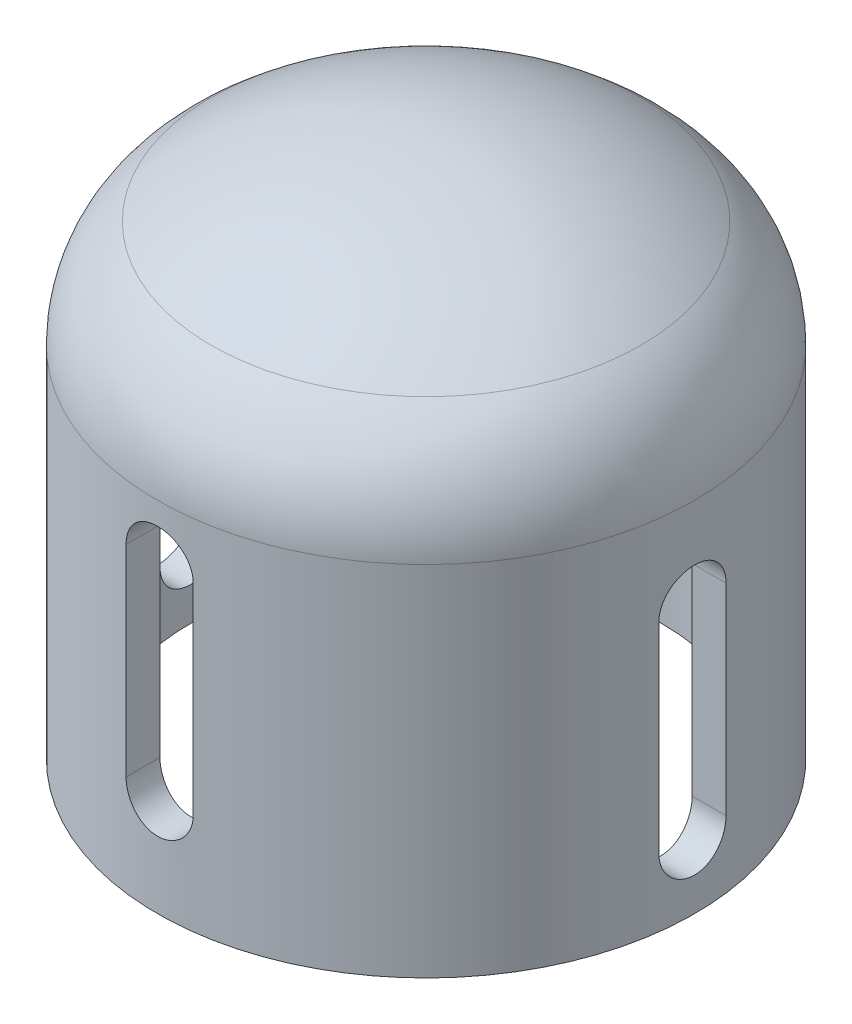
from build123d import *

# Parameters (mm, degrees)
TAGLIO_ESTRUSIONE1_DEPTH      = 21.0000001
TAGLIO_ESTRUSIONE1_DEPTH_BACK = 21.0000001
TAGLIO_ESTRUSIONE2_DEPTH      = 21.0000001
TAGLIO_ESTRUSIONE2_DEPTH_BACK = 21.0000001


with BuildPart() as part:
    # Schizzo1 → Rivoluzione1 (revolve)
    with BuildSketch(Plane.XY, mode=Mode.PRIVATE) as rivoluzione1_sk:
        with BuildLine():
            Line((20, 26.666666667), (20, 0))
            Line((20, 0), (17.5, 0))
            Line((17.5, 0), (17.5, 27.862996478))
            ThreePointArc((17.5, 27.862996478), (17.044466296, 29.948140619), (15.760869565, 31.653343386))
            ThreePointArc((15.760869565, 31.653343386), (8.40518297, 35.991238731), (0, 37.5))
            Line((0, 37.5), (0, 40))
            ThreePointArc((0, 40), (8.432740427, 38.631554615), (16, 34.666666667))
            ThreePointArc((16, 34.666666667), (18.94427191, 31.138802622), (20, 26.666666667))
        make_face()
    revolve(rivoluzione1_sk.sketch.rotate(Axis((0, 0, 0), (0, 1, 0)), 90), axis=Axis((0, 0, 0), (0, 1, 0)))  # turned: the seam where the file's is

    # Schizzo2 → Taglio-Estrusione1 (cut, two sides)
    with BuildSketch(Plane.XY) as taglio_estrusione1_sk:
        with BuildLine():
            Line((2.5, 22.5), (2.5, 7.5))
            ThreePointArc((2.5, 7.5), (0, 5), (-2.5, 7.5))
            Line((-2.5, 7.5), (-2.5, 22.5))
            ThreePointArc((-2.5, 22.5), (0, 25), (2.5, 22.5))
        make_face()
    extrude(amount=TAGLIO_ESTRUSIONE1_DEPTH, mode=Mode.SUBTRACT)
    extrude(taglio_estrusione1_sk.sketch, amount=-TAGLIO_ESTRUSIONE1_DEPTH_BACK, mode=Mode.SUBTRACT)

    # Schizzo3 → Taglio-Estrusione2 (cut, two sides)
    with BuildSketch(Plane(origin=(0, 0, 0), x_dir=(0, 0, -1), z_dir=(1, 0, 0))) as taglio_estrusione2_sk:
        with BuildLine():
            Line((2.5, 20), (2.5, 5))
            ThreePointArc((2.5, 5), (0, 2.5), (-2.5, 5))
            Line((-2.5, 5), (-2.5, 20))
            ThreePointArc((-2.5, 20), (0, 22.5), (2.5, 20))
        make_face()
    extrude(amount=TAGLIO_ESTRUSIONE2_DEPTH, mode=Mode.SUBTRACT)
    extrude(taglio_estrusione2_sk.sketch, amount=-TAGLIO_ESTRUSIONE2_DEPTH_BACK, mode=Mode.SUBTRACT)


solid = part.part
